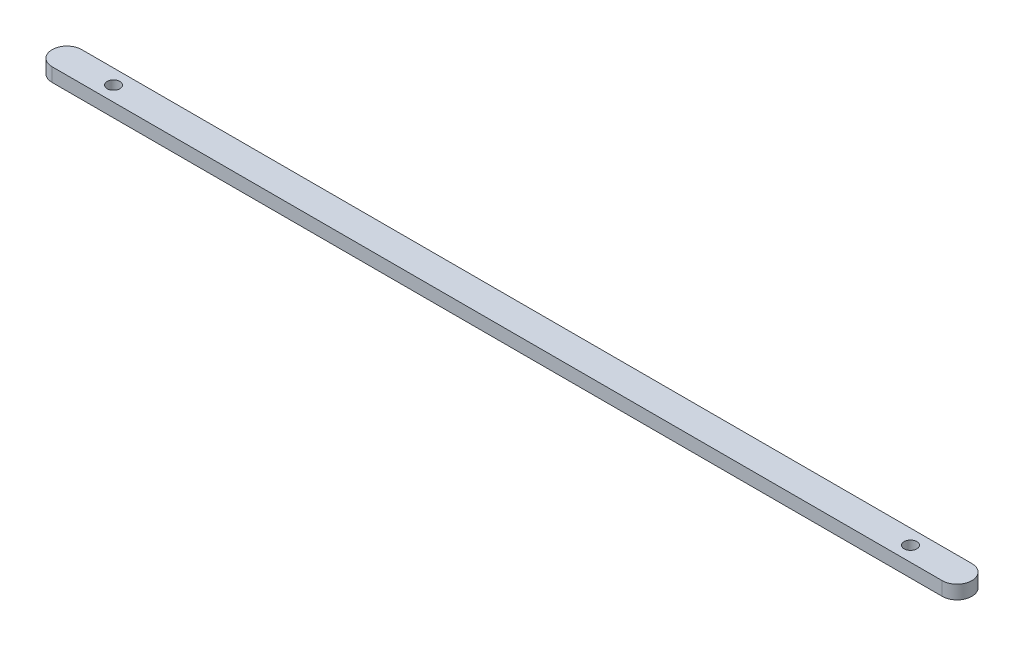
from build123d import *

# Parameters (mm, degrees)
SKETCH1_R           = 1.5
BOSS_EXTRUDE2_DEPTH = 1.61


with BuildPart() as part:
    # Sketch1 → Boss-Extrude2 (new body, symmetric)
    with BuildSketch(Plane(origin=(0, 0, 0), x_dir=(1, 0, 0), z_dir=(0, 1, 0))):
        with BuildLine():
            Line((-105.08, 3.5), (105.08, 3.5))
            ThreePointArc((105.08, 3.5), (108.58, 0), (105.08, -3.5))
            Line((105.08, -3.5), (-105.08, -3.5))
            ThreePointArc((-105.08, -3.5), (-108.58, 0), (-105.08, 3.5))
        make_face()
        with Locations((-94.08, 0)):
            Circle(SKETCH1_R, mode=Mode.SUBTRACT)
        with Locations((94.08, 0)):
            Circle(SKETCH1_R, mode=Mode.SUBTRACT)
    extrude(amount=BOSS_EXTRUDE2_DEPTH, both=True)


solid = part.part
